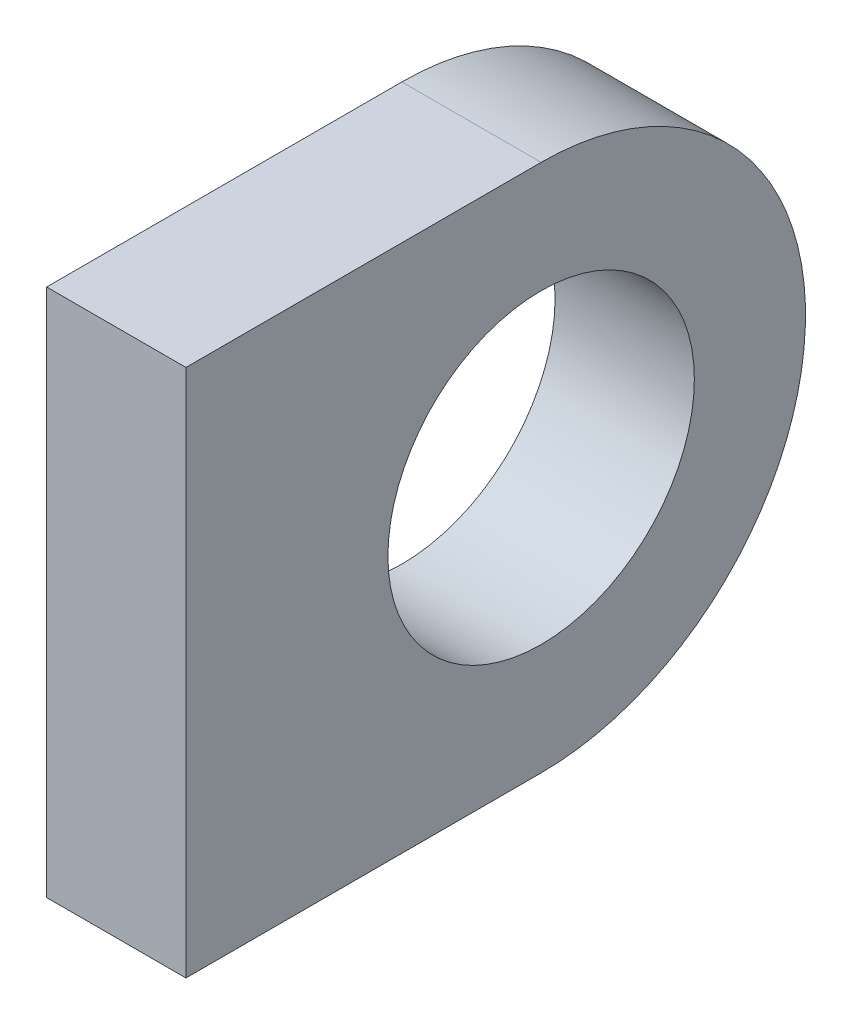
from build123d import *

# Parameters (mm, degrees)
BOSS_EXTRUDE1_DEPTH = 10
SKETCH2_R           = 11
CUT_EXTRUDE1_DEPTH  = 10
BOSS_EXTRUDE2_START = -37.960973
SKETCH3_W           = 10
SKETCH3_H           = 2
BOSS_EXTRUDE2_DEPTH = 37.960973


with BuildPart() as part:
    # Sketch1 → Boss-Extrude1 (new body)
    with BuildSketch(Plane(origin=(0, 0, 0), x_dir=(0, 0, -1), z_dir=(1, 0, 0))):
        with BuildLine():
            Line((-23.5, 18.980486252), (0, 18.980486252))
            ThreePointArc((0, 18.980486252), (18.980486252, 0), (0, -18.980486252))
            Line((0, -18.980486252), (-23.5, -18.980486252))
            Line((-23.5, -18.980486252), (-23.5, 18.980486252))
        make_face()
    extrude(amount=BOSS_EXTRUDE1_DEPTH)

    # Sketch2 → Cut-Extrude1 (cut)
    with BuildSketch(Plane.ZY):
        Circle(SKETCH2_R)
    extrude(amount=-CUT_EXTRUDE1_DEPTH, mode=Mode.SUBTRACT)

    # Sketch3 → Boss-Extrude2 (add)
    with BuildSketch(Plane(origin=(0, 18.980486252, 0), x_dir=(1, 0, 0), z_dir=(0, 1, 0)).offset(BOSS_EXTRUDE2_START)):
        with Locations((5, -24.5)):
            Rectangle(SKETCH3_W, SKETCH3_H)
    extrude(amount=BOSS_EXTRUDE2_DEPTH)


solid = part.part
